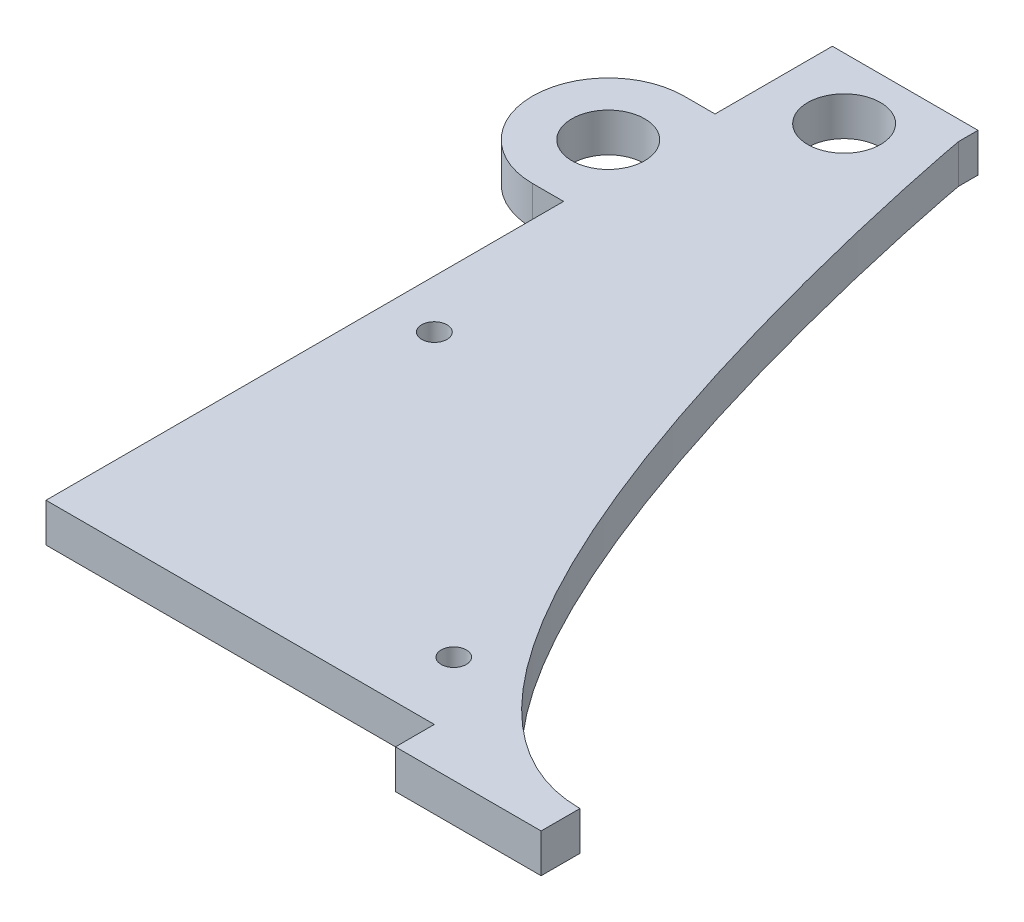
from build123d import *

# Parameters (mm, degrees)
SKETCH1_R               = 4.7625
BOSS_EXTRUDE1_DEPTH     = 5.08
SKETCH4_W               = 19.05
SKETCH4_H               = 5.08
BOSS_EXTRUDE2_DEPTH     = 5.08
SKETCH5_R               = 1.651
SKETCH5_R_2             = 1.660728382
CUT_EXTRUDE1_DEPTH      = 1.0000001
CUT_EXTRUDE1_DEPTH_BACK = 6.0800001
SKETCH6_R               = 4.7625
BOSS_EXTRUDE3_DEPTH     = 5.08
SKETCH8_R               = 4.7625
CUT_EXTRUDE2_DEPTH      = 6.0800001


with BuildPart() as part:
    # Sketch1 → Boss-Extrude1 (new body)
    with BuildSketch(Plane(origin=(0, 0, 0), x_dir=(1, 0, 0), z_dir=(0, 1, 0))):
        with BuildLine():
            Line((-9.525, 53.975), (9.525, 53.975))
            Line((9.525, 53.975), (9.525, 51.435))
            add(Edge.make_bspline(
                [(9.525, 51.435), (9.525, 51.21454564), (27.819109584, -48.895), (60.325, -48.895)],
                knots=[0, 0, 0, 0, 1, 1, 1, 1], degree=3))
            Line((60.325, -48.895), (-9.525, -48.895))
            Line((-9.525, -48.895), (-9.525, 53.975))
        make_face()
        with Locations((0, 45.9867)):
            Circle(SKETCH1_R, mode=Mode.SUBTRACT)
    extrude(amount=BOSS_EXTRUDE1_DEPTH)

    # Sketch4 → Boss-Extrude2 (add)
    with BuildSketch(Plane(origin=(0, 5.08, 0), x_dir=(1, 0, 0), z_dir=(0, 1, 0))):
        with Locations((50.8, -51.435)):
            Rectangle(SKETCH4_W, SKETCH4_H)
    extrude(amount=-BOSS_EXTRUDE2_DEPTH)

    # Sketch5 → Cut-Extrude1 (cut, two sides)
    with BuildSketch(Plane.XZ) as cut_extrude1_sk:
        with Locations((34.925, 40.005)):
            Circle(SKETCH5_R)
        with Locations((-3.175, 4.445)):
            Circle(SKETCH5_R_2)
    extrude(amount=CUT_EXTRUDE1_DEPTH, mode=Mode.SUBTRACT)
    extrude(cut_extrude1_sk.sketch, amount=-CUT_EXTRUDE1_DEPTH_BACK, mode=Mode.SUBTRACT)

    # Sketch6 → Boss-Extrude3 (add)
    with BuildSketch(Plane.XZ):
        with BuildLine():
            Line((-13.589, -18.81432439), (-9.525, -18.81432439))
            Line((-9.525, -18.81432439), (-9.525, -19.686347414))
            ThreePointArc((-9.525, -19.686347414), (-3.683, -28.72032439), (-9.525, -37.754301365))
            Line((-9.525, -37.754301365), (-9.525, -38.62632439))
            Line((-9.525, -38.62632439), (-13.589, -38.62632439))
            ThreePointArc((-13.589, -38.62632439), (-23.495, -28.72032439), (-13.589, -18.81432439))
        make_face()
        with Locations((-13.589, -28.72032439)):
            Circle(SKETCH6_R, mode=Mode.SUBTRACT)
    extrude(amount=-BOSS_EXTRUDE3_DEPTH)

    # Sketch8 → Cut-Extrude2 (cut, through all)
    with BuildSketch(Plane(origin=(0, 5.08, 0), x_dir=(1, 0, 0), z_dir=(0, 1, 0))):
        with Locations((-13.589, 28.72032439)):
            Circle(SKETCH8_R)
    extrude(amount=-CUT_EXTRUDE2_DEPTH, mode=Mode.SUBTRACT)


solid = part.part
